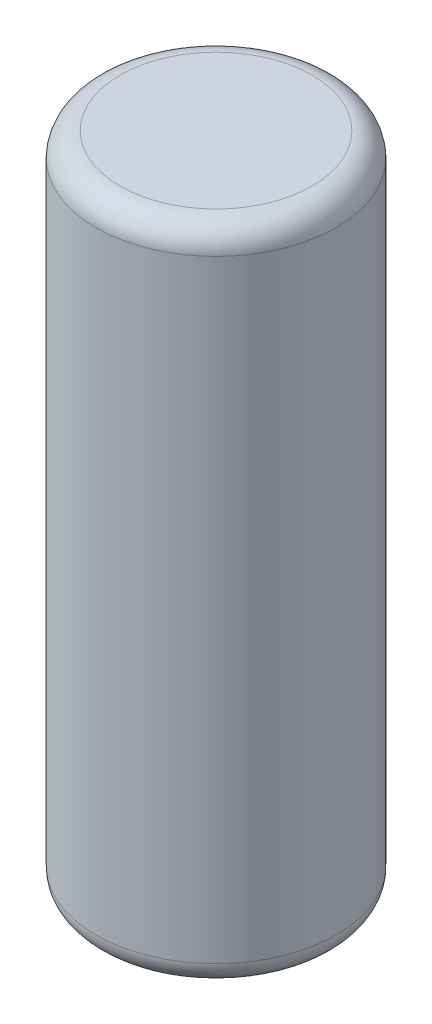
from build123d import *

# Parameters (mm, degrees)
SKETCH1_R           = 50
BOSS_EXTRUDE1_DEPTH = 275
FILLET1_R           = 10


with BuildPart() as part:
    # Sketch1 → Boss-Extrude1 (new body)
    with BuildSketch(Plane(origin=(0, 0, 0), x_dir=(1, 0, 0), z_dir=(0, 1, 0))):
        Circle(SKETCH1_R)
    extrude(amount=BOSS_EXTRUDE1_DEPTH)

    # Fillet1
    fillet1_edges = [part.edges().sort_by_distance(p)[0] for p in [
        (-50, 0, 0),
        (-50, 275, 0),
    ]]
    fillet(fillet1_edges, radius=FILLET1_R)


solid = part.part
